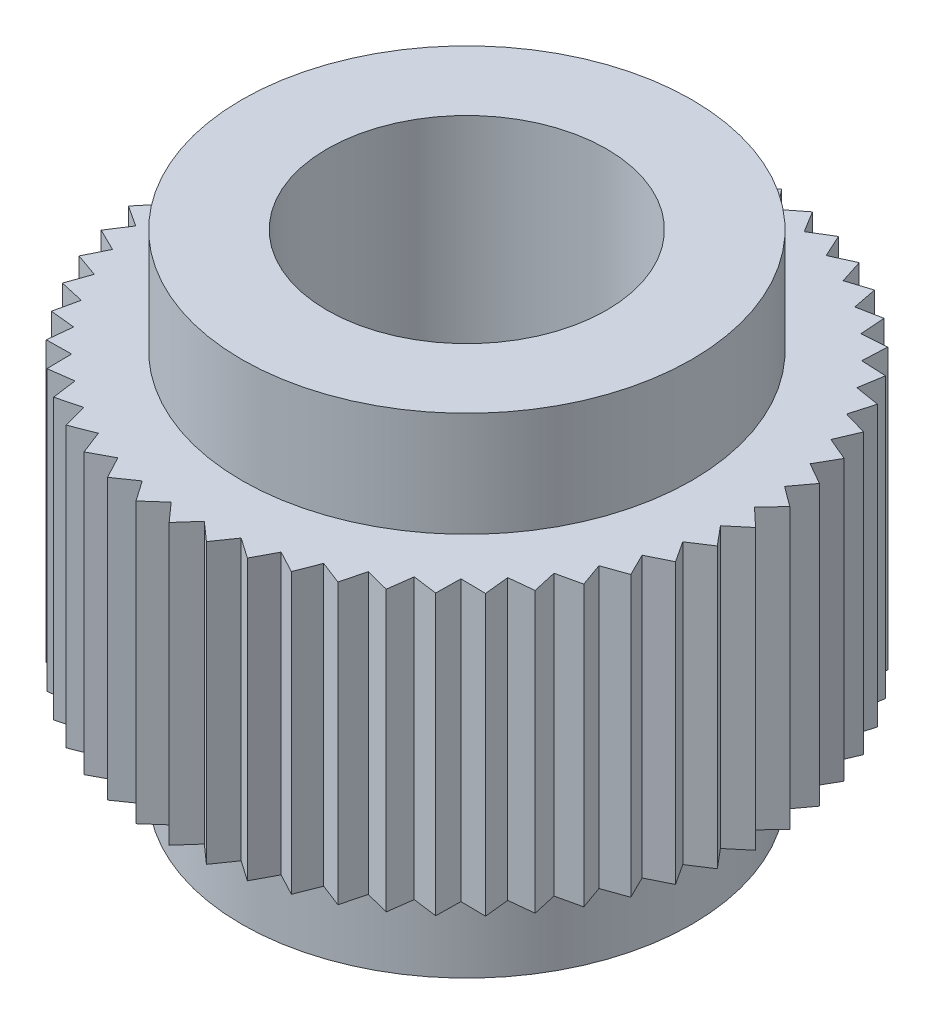
from build123d import *

# Parameters (mm, degrees)
CUT_EXTRUDE_2_DEPTH      = 12
PATTERN_CIRCULAR_1_COUNT = 53
SKETCH_4_R               = 4
CUT_EXTRUDE_3_DEPTH      = 18


with BuildPart() as part:
    # 草图1 → 旋转1 (revolve)
    with BuildSketch(Plane.XY):
        Polygon((0, 17), (4, 17), (4, 14), (6.44, 14), (6.44, 11), (9.5, 11), (9.5, 3), (6.44, 3), (6.44, 0), (0, 0), align=None)
    revolve(axis=Axis((0, 17, 0), (0, -1, 0)))

    # 草图2 → 切除-拉伸2 (cut, through all)
    with BuildSketch(Plane(origin=(0, 11, 0), x_dir=(1, 0, 0), z_dir=(0, 1, 0))):
        with BuildLine():
            Line((0, 8), (1.396758286, 9.396758286))
            ThreePointArc((1.396758286, 9.396758286), (0, 9.5), (-1.396758286, 9.396758286))
            Line((-1.396758286, 9.396758286), (0, 8))
        make_face()
    cut_extrude_2 = extrude(amount=-CUT_EXTRUDE_2_DEPTH, mode=Mode.SUBTRACT)

    # 阵列(圆周)1: 切除-拉伸2 ×53 about axis
    pattern_circular_1_axis = Axis((0, 0, 0), (0, 1, 0))
    for i in range(1, PATTERN_CIRCULAR_1_COUNT):
        add(cut_extrude_2.rotate(pattern_circular_1_axis, i * 360 / PATTERN_CIRCULAR_1_COUNT), mode=Mode.SUBTRACT)

    # 草图4 → 切除-拉伸3 (cut, through all)
    with BuildSketch(Plane(origin=(0, 17, 0), x_dir=(1, 0, 0), z_dir=(0, 1, 0))):
        Circle(SKETCH_4_R)
    extrude(amount=-CUT_EXTRUDE_3_DEPTH, mode=Mode.SUBTRACT)


solid = part.part
